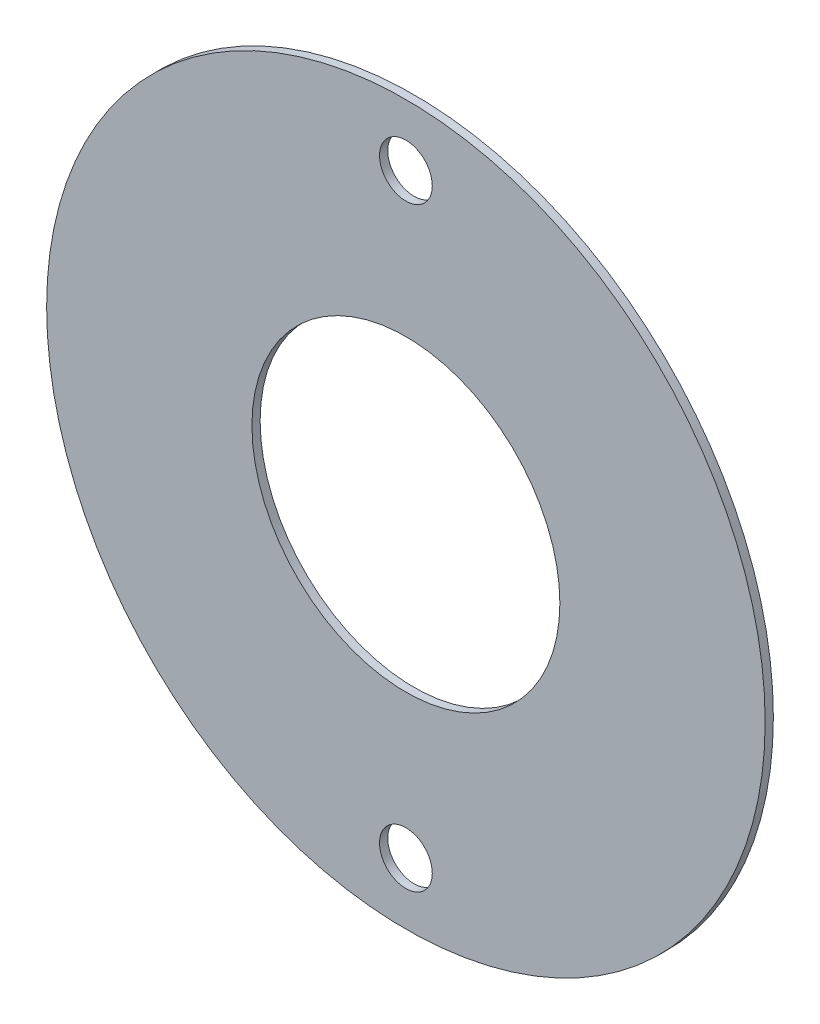
from build123d import *

# Parameters (mm, degrees)
SKETCH1_R                    = 22.225
BOSS_EXTRUDE1_DEPTH          = 0.508
SKETCH2_R                    = 9.525
CUT_EXTRUDE1_DEPTH           = 1.508
F_30_0_1285_DIAMETER_HOLE1_D = 3.2639


with BuildPart() as part:
    # Sketch1 → Boss-Extrude1 (new body)
    with BuildSketch(Plane.XY):
        Circle(SKETCH1_R)
    extrude(amount=BOSS_EXTRUDE1_DEPTH)

    # Sketch2 → Cut-Extrude1 (cut, through all)
    with BuildSketch(Plane.XY.offset(0.508)):
        Circle(SKETCH2_R)
    extrude(amount=-CUT_EXTRUDE1_DEPTH, mode=Mode.SUBTRACT)

    # #30 (0.1285) Diameter Hole1 (through all)
    with Locations(Plane.XY.offset(0.508)):
        with Locations((0, 18.415)):
            f_30_0_1285_diameter_hole1 = Hole(F_30_0_1285_DIAMETER_HOLE1_D / 2)

    # Mirror1: #30 (0.1285) Diameter Hole1 across plane
    add(f_30_0_1285_diameter_hole1.mirror(Plane.ZX), mode=Mode.SUBTRACT)


solid = part.part
